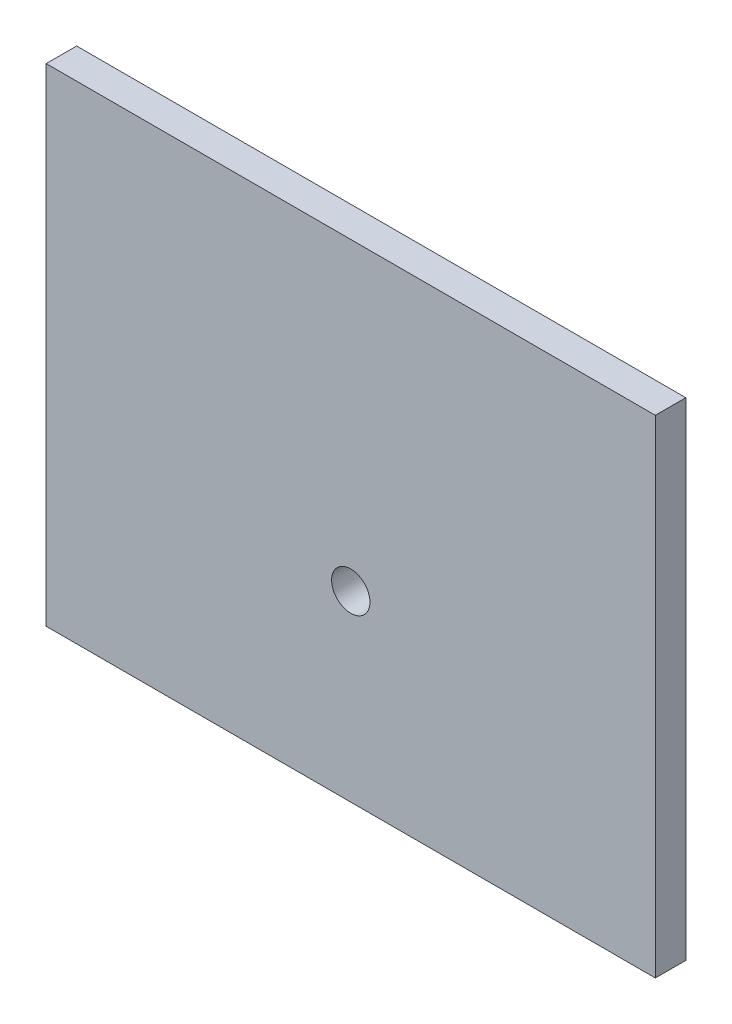
from build123d import *

# Parameters (mm, degrees)
SKETCH1_W           = 127
SKETCH1_H           = 101.6
SKETCH1_R           = 4
BOSS_EXTRUDE1_DEPTH = 6.35


with BuildPart() as part:
    # Sketch1 → Boss-Extrude1 (new body)
    with BuildSketch(Plane.XY):
        with Locations((63.5, 50.8)):
            Rectangle(SKETCH1_W, SKETCH1_H)
        with Locations((63.5, 38.1)):
            Circle(SKETCH1_R, mode=Mode.SUBTRACT)
    extrude(amount=BOSS_EXTRUDE1_DEPTH)


solid = part.part
